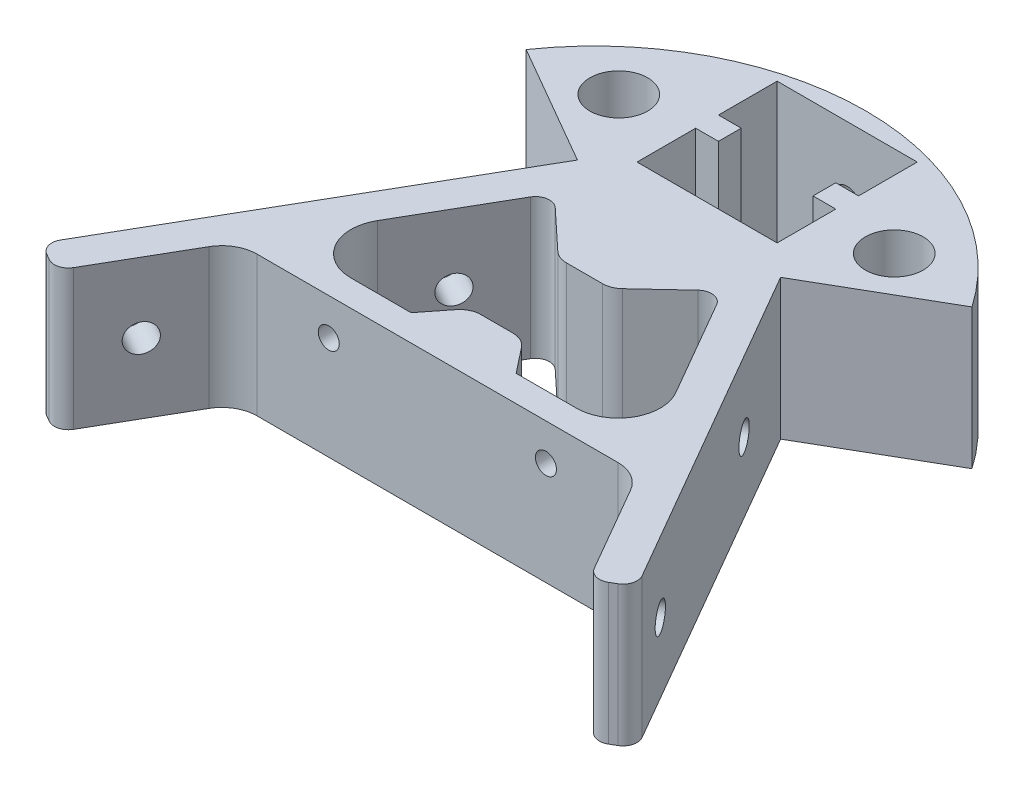
from build123d import *

# Parameters (mm, degrees)
SKETCH1_R                      = 4.125
BOSS_EXTRUDE1_DEPTH            = 20
FILLET2_R                      = 5
FILLET3_R                      = 5
FILLET4_R                      = 6
FILLET5_R                      = 6
FILLET6_R                      = 2
FILLET7_R                      = 3
FILLET10_R                     = 2
F_8_0_199_DIAMETER_HOLE2_D     = 4
F_8_0_199_DIAMETER_HOLE3_D     = 4
SKETCH12_W                     = 2
SKETCH12_H                     = 41.945563192
SKETCH16_W                     = 2
SKETCH16_H                     = 41.945563192
F_8_0_199_DIAMETER_HOLE8_D     = 3.000000096
F_8_0_199_DIAMETER_HOLE8_DEPTH = 4
F_8_0_199_DIAMETER_HOLE8_TIP   = 0.901290957


with BuildPart() as part:
    # Sketch1 → Boss-Extrude1 (new body)
    with BuildSketch(Plane(origin=(0, 0, 0), x_dir=(1, 0, 0), z_dir=(0, 1, 0))):
        with BuildLine():
            Line((-28.643593539, -10.537386441), (-38.169872981, -27.037386441))
            Line((-38.169872981, -27.037386441), (-42.5, -24.537386441))
            Line((-42.5, -24.537386441), (-14.5, 23.960036171))
            Line((-14.5, 23.960036171), (-31.820508076, 33.960036171))
            ThreePointArc((-31.820508076, 33.960036171), (0, 50.621689136), (31.820508076, 33.960036171))
            Line((31.820508076, 33.960036171), (14.5, 23.960036171))
            Line((14.5, 23.960036171), (42.5, -24.537386441))
            Line((42.5, -24.537386441), (38.169872981, -27.037386441))
            Line((38.169872981, -27.037386441), (28.643593539, -10.537386441))
            Line((28.643593539, -10.537386441), (-28.643593539, -10.537386441))
        make_face()
        with Locations((19.660254038, 35.022213998)):
            Circle(SKETCH1_R, mode=Mode.SUBTRACT)
        with Locations((-19.660254038, 35.022213998)):
            Circle(SKETCH1_R, mode=Mode.SUBTRACT)
        Polygon((-12.0447733, 18.212613559), (-26.47853003, -6.787386441), (-7.5, -6.787386441), (-3.75, -2.037386441), (3.75, -2.037386441), (7.5, -6.787386441), (26.47853003, -6.787386441), (12.0447733, 18.212613559), (3.75, 10.462613559), (-3.75, 10.462613559), align=None, mode=Mode.SUBTRACT)
        Polygon((-9.999491924, 47.962613559), (10.000508076, 47.962613559), (10.000508076, 39.587613559), (6.750508076, 39.587613559), (6.750508076, 36.337613559), (10.000508076, 36.337613559), (10.000508076, 27.962613559), (-9.999491924, 27.962613559), (-9.999491924, 36.337613559), (-6.749491924, 36.337613559), (-6.749491924, 39.587613559), (-9.999491924, 39.587613559), align=None, mode=Mode.SUBTRACT)
    extrude(amount=BOSS_EXTRUDE1_DEPTH)

    # Fillet2
    fillet2_edges = [part.edges().sort_by_distance(p)[0] for p in [
        (-28.643593539, 10, 10.537386441),
    ]]
    fillet(fillet2_edges, radius=FILLET2_R)

    # Fillet3
    fillet3_edges = [part.edges().sort_by_distance(p)[0] for p in [
        (28.643593539, 10, 10.537386441),
    ]]
    fillet(fillet3_edges, radius=FILLET3_R)

    # Fillet4
    fillet4_edges = [part.edges().sort_by_distance(p)[0] for p in [
        (-26.47853003, 10, 6.787386441),
    ]]
    fillet(fillet4_edges, radius=FILLET4_R)

    # Fillet5
    fillet5_edges = [part.edges().sort_by_distance(p)[0] for p in [
        (26.47853003, 10, 6.787386441),
    ]]
    fillet(fillet5_edges, radius=FILLET5_R)

    # Fillet6
    fillet6_edges = [part.edges().sort_by_distance(p)[0] for p in [
        (-12.0447733, 10, -18.212613559),
        (12.0447733, 10, -18.212613559),
    ]]
    fillet(fillet6_edges, radius=FILLET6_R)

    # Fillet7
    fillet7_edges = [part.edges().sort_by_distance(p)[0] for p in [
        (-3.75, 10, -10.462613559),
        (-3.75, 10, 2.037386441),
        (3.75, 10, 2.037386441),
        (3.75, 10, -10.462613559),
    ]]
    fillet(fillet7_edges, radius=FILLET7_R)

    # Fillet10
    fillet10_edges = [part.edges().sort_by_distance(p)[0] for p in [
        (-38.169872981, 10, 27.037386441),
        (-42.5, 10, 24.537386441),
        (42.5, 10, 24.537386441),
        (38.169872981, 10, 27.037386441),
    ]]
    fillet(fillet10_edges, radius=FILLET10_R)

    # #8 (0.199) Diameter Hole2 (through all)
    with Locations(Plane(origin=(16.919872981, 0, -9.76869322), x_dir=(0.5, 0, 0.866025404), z_dir=(-0.866025404, 0, 0.5))):
        with Locations((33.417096231, 10)):
            Hole(F_8_0_199_DIAMETER_HOLE2_D / 2)

    # #8 (0.199) Diameter Hole3 (through all)
    with Locations(Plane(origin=(-16.919872981, 0, -9.76869322), x_dir=(0.5, 0, -0.866025404), z_dir=(0.866025404, 0, 0.5))):
        with Locations((-33.417096231, 10)):
            Hole(F_8_0_199_DIAMETER_HOLE3_D / 2)

    # Sketch12 → #8 (0.199) Diameter Hole5 (revolve, cut)
    with BuildSketch(Plane(origin=(17.292785365, 10, -9.122790024), x_dir=(0.5, 0, 0.866025404), z_dir=(0, 1, 0))):
        with Locations((1, 20.972781596)):
            Rectangle(SKETCH12_W, SKETCH12_H)
    revolve(axis=Axis((11.793524051, 10, -5.947790024), (0.866025404, 0, -0.5)), mode=Mode.SUBTRACT)

    # Sketch16 → #8 (0.199) Diameter Hole6 (revolve, cut)
    with BuildSketch(Plane(origin=(-17.292785365, 10, -9.122790024), x_dir=(0.5, 0, -0.866025404), z_dir=(0, 1, 0))):
        with Locations((1, 20.972781596)):
            Rectangle(SKETCH16_W, SKETCH16_H)
    revolve(axis=Axis((-11.793524051, 10, -5.947790024), (-0.866025404, 0, -0.5)), mode=Mode.SUBTRACT)

    # Sketch18 → #8 (0.199) Diameter Hole7 (revolve, cut)
    with BuildSketch(Plane(origin=(0.000508076, 10, -47.962613559), x_dir=(0, -1, 0), z_dir=(1, 0, 0))):
        Polygon((0, 0), (0, 31.2017212), (1.999999937, 30), (1.999999937, 0), align=None)
    revolve(axis=Axis((0.000508076, 10, -41.612613559), (0, 0, -1)), mode=Mode.SUBTRACT)

    # #8 (0.199) Diameter Hole8
    with Locations(Plane.XY.offset(10.537386441)):
        with Locations((-15.499957804, 14.75), (15.500042196, 14.75)):
            Hole(F_8_0_199_DIAMETER_HOLE8_D / 2, depth=F_8_0_199_DIAMETER_HOLE8_DEPTH)
            with Locations((0, 0, -(F_8_0_199_DIAMETER_HOLE8_DEPTH + F_8_0_199_DIAMETER_HOLE8_TIP / 2))):  # 118° drill point
                Cone(0, F_8_0_199_DIAMETER_HOLE8_D / 2, F_8_0_199_DIAMETER_HOLE8_TIP, mode=Mode.SUBTRACT)


solid = part.part
